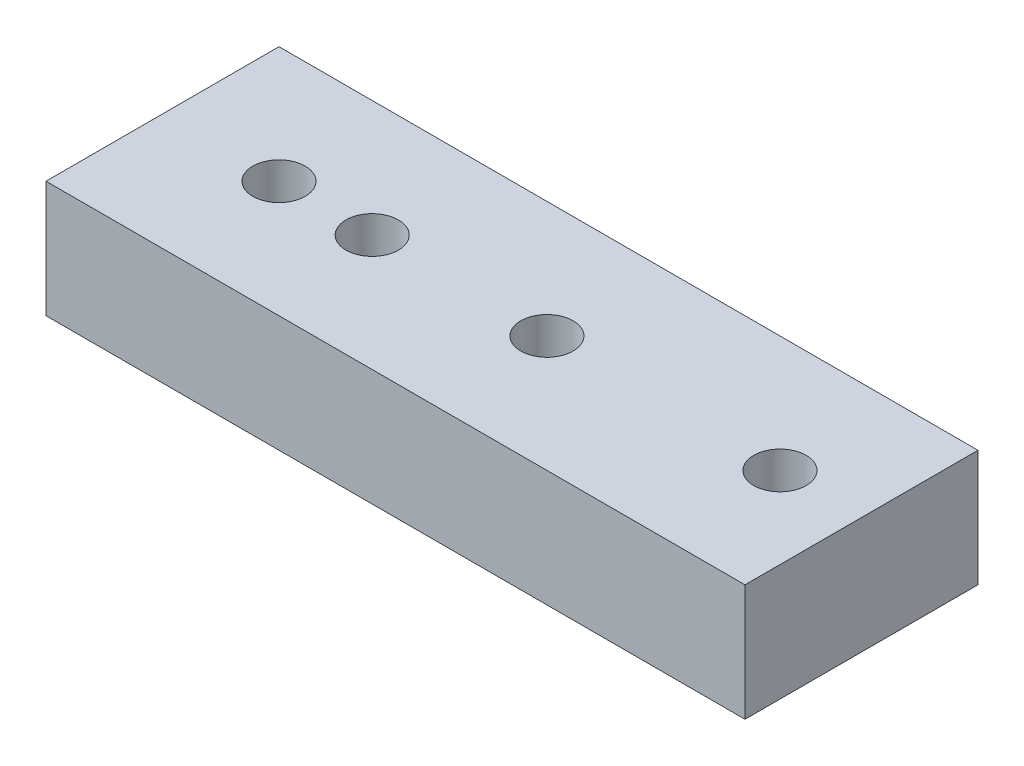
from build123d import *

# Parameters (mm, degrees)
SKETCH1_W           = 60
SKETCH1_H           = 20
SKETCH1_R           = 2.25
BOSS_EXTRUDE1_DEPTH = 10
CUT_EXTRUDE1_DEPTH  = 3.2


with BuildPart() as part:
    # Sketch1 → Boss-Extrude1 (new body)
    with BuildSketch(Plane(origin=(0, 0, 0), x_dir=(1, 0, 0), z_dir=(0, 1, 0))):
        with Locations((12, 0)):
            Rectangle(SKETCH1_W, SKETCH1_H)
        Circle(SKETCH1_R, mode=Mode.SUBTRACT)
        with Locations((-8, 0)):
            Circle(SKETCH1_R, mode=Mode.SUBTRACT)
        with Locations((35, 0)):
            Circle(SKETCH1_R, mode=Mode.SUBTRACT)
        with Locations((15, 0)):
            Circle(SKETCH1_R, mode=Mode.SUBTRACT)
    extrude(amount=BOSS_EXTRUDE1_DEPTH)

    # Sketch2 → Cut-Extrude1 (cut)
    with BuildSketch(Plane.XZ):
        Polygon((-3.5, 2.020725942), (-3.5, -2.020725942), (0, -4.041451884), (3.5, -2.020725942), (3.5, 2.020725942), (0, 4.041451884), align=None)
        Polygon((-4.5, 2.020725942), (-8, 4.041451884), (-11.5, 2.020725942), (-11.5, -2.020725942), (-8, -4.041451884), (-4.5, -2.020725942), align=None)
    extrude(amount=-CUT_EXTRUDE1_DEPTH, mode=Mode.SUBTRACT)


solid = part.part
